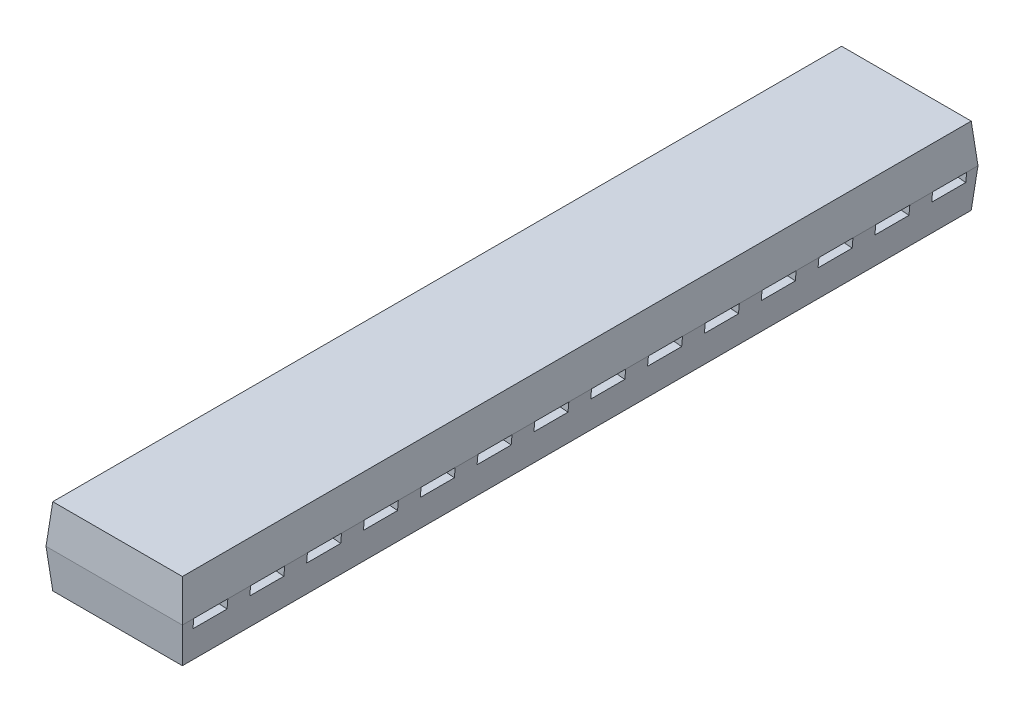
from build123d import *

# Parameters (mm, degrees)
SKETCH1_W                     = 6
SKETCH1_H                     = 35
BOSS_EXTRUDE1_DEPTH           = 1.7
BOSS_EXTRUDE1_TAPER           = 5
BOSS_EXTRUDE1_OTHER_WAY_DEPTH = 1.7
BOSS_EXTRUDE1_OTHER_WAY_TAPER = 5
SKETCH2_W                     = 1.5
SKETCH2_H                     = 0.41
CUT_EXTRUDE1_DEPTH            = 1.7


with BuildPart() as part:
    # Sketch1 → Boss-Extrude1 (new body)
    with BuildSketch(Plane(origin=(0, 0, 0), x_dir=(1, 0, 0), z_dir=(0, 1, 0))):
        with Locations((3, 17.5)):
            Rectangle(SKETCH1_W, SKETCH1_H)
    extrude(amount=BOSS_EXTRUDE1_DEPTH, taper=BOSS_EXTRUDE1_TAPER)

    # Sketch1 → Boss-Extrude1 other way (add)
    with BuildSketch(Plane(origin=(0, 0, 0), x_dir=(1, 0, 0), z_dir=(0, 1, 0))):
        with Locations((3, 17.5)):
            Rectangle(SKETCH1_W, SKETCH1_H)
    extrude(amount=-BOSS_EXTRUDE1_OTHER_WAY_DEPTH, taper=BOSS_EXTRUDE1_OTHER_WAY_TAPER)

    # Sketch2 → Cut-Extrude1 (cut)
    with BuildSketch(Plane(origin=(5.954423259, -0.520944533, 0), x_dir=(0, 0, -1), z_dir=(0.996194698, -0.087155743, 0))):
        with Locations((1.25, 0.317934456)):
            Rectangle(SKETCH2_W, SKETCH2_H)
        with Locations((3.75, 0.317934456)):
            Rectangle(SKETCH2_W, SKETCH2_H)
        with Locations((6.25, 0.317934456)):
            Rectangle(SKETCH2_W, SKETCH2_H)
        with Locations((8.75, 0.317934456)):
            Rectangle(SKETCH2_W, SKETCH2_H)
        with Locations((11.25, 0.317934456)):
            Rectangle(SKETCH2_W, SKETCH2_H)
        with Locations((13.75, 0.317934456)):
            Rectangle(SKETCH2_W, SKETCH2_H)
        with Locations((16.25, 0.317934456)):
            Rectangle(SKETCH2_W, SKETCH2_H)
        with Locations((18.75, 0.317934456)):
            Rectangle(SKETCH2_W, SKETCH2_H)
        with Locations((21.25, 0.317934456)):
            Rectangle(SKETCH2_W, SKETCH2_H)
        with Locations((23.75, 0.317934456)):
            Rectangle(SKETCH2_W, SKETCH2_H)
        with Locations((26.25, 0.317934456)):
            Rectangle(SKETCH2_W, SKETCH2_H)
        with Locations((28.75, 0.317934456)):
            Rectangle(SKETCH2_W, SKETCH2_H)
        with Locations((31.25, 0.317934456)):
            Rectangle(SKETCH2_W, SKETCH2_H)
        with Locations((33.75, 0.317934456)):
            Rectangle(SKETCH2_W, SKETCH2_H)
    cut_extrude1 = extrude(amount=-CUT_EXTRUDE1_DEPTH, mode=Mode.SUBTRACT)

    # Mirror1: Cut-Extrude1 across plane
    add(cut_extrude1.mirror(Plane(origin=(3, 0, 0), x_dir=(0, 0, 1), z_dir=(1, 0, 0))), mode=Mode.SUBTRACT)


solid = part.part
